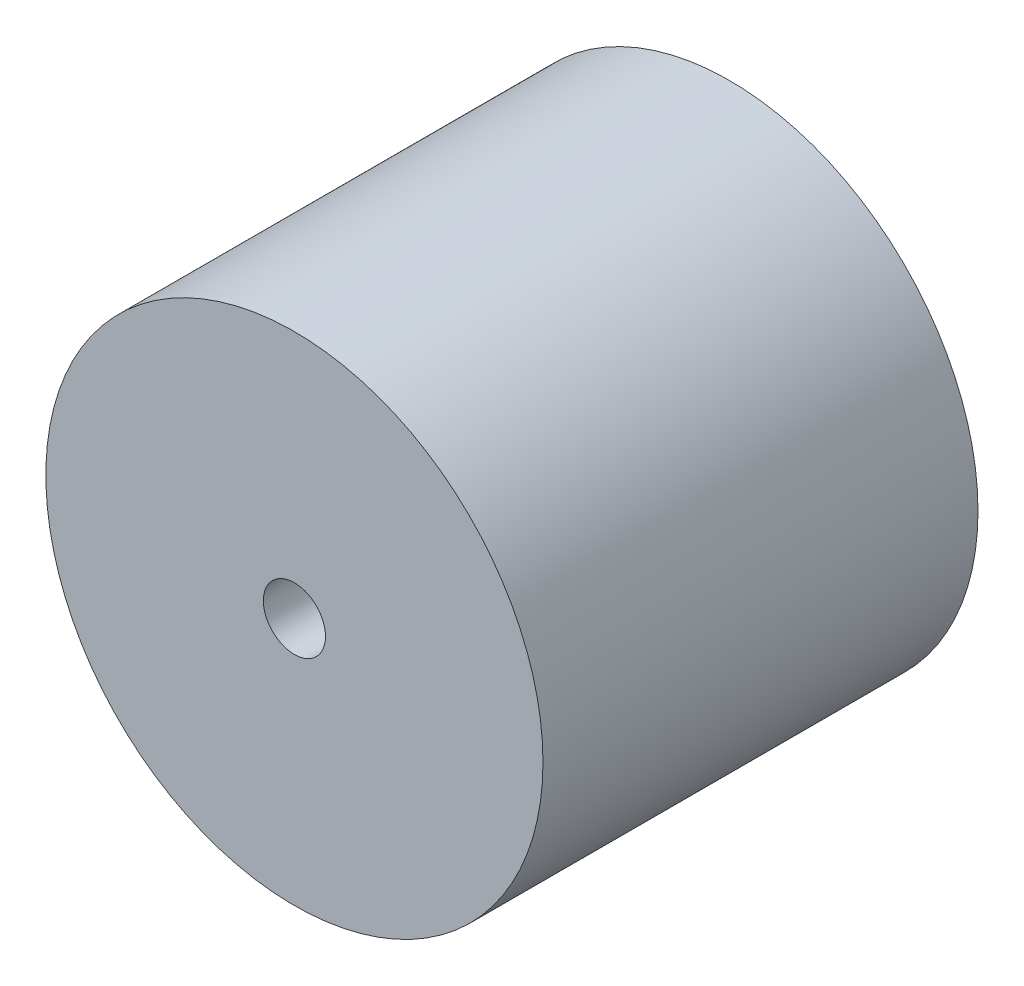
from build123d import *

# Parameters (mm, degrees)
SKETCH1_R           = 20
SKETCH1_R_2         = 2.5
BOSS_EXTRUDE1_DEPTH = 35


with BuildPart() as part:
    # Sketch1 → Boss-Extrude1 (new body)
    with BuildSketch(Plane.XY):
        Circle(SKETCH1_R)
        Circle(SKETCH1_R_2, mode=Mode.SUBTRACT)
    extrude(amount=BOSS_EXTRUDE1_DEPTH)


solid = part.part
